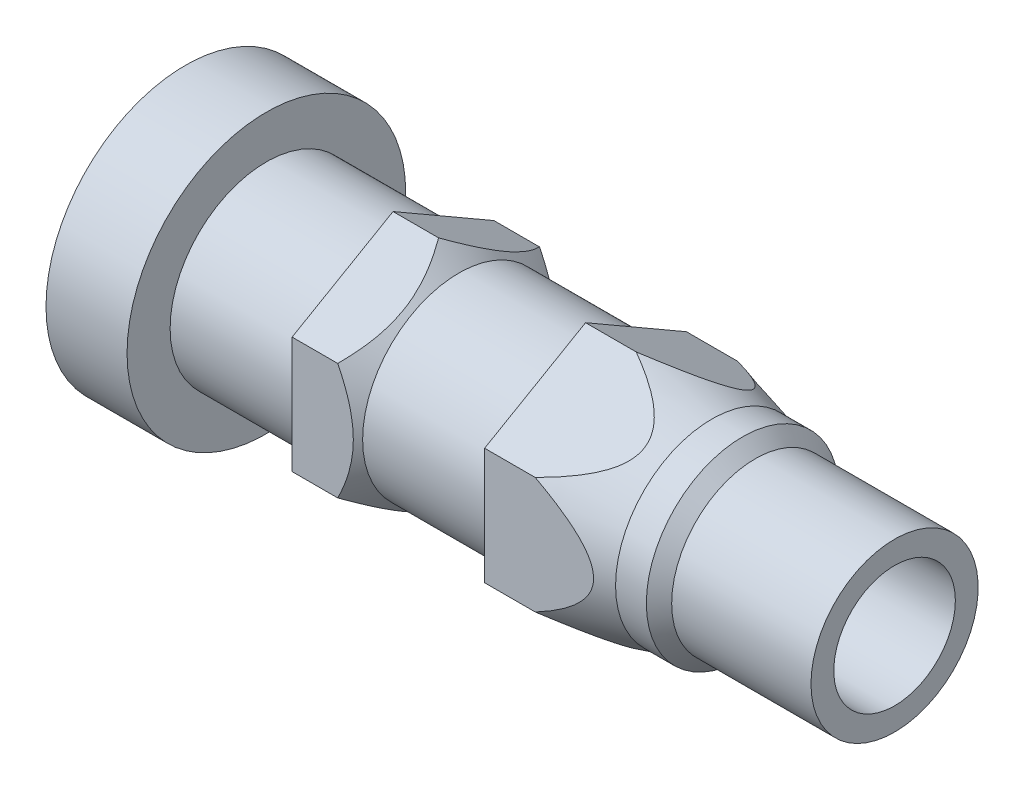
from build123d import *

# Parameters (mm, degrees)
HOLE1_D               = 0.7874
HOLE1_DEPTH           = 2.286
HOLE1_CSINK_D         = 1.016
HOLE1_CSINK_ANGLE     = 60
HOLE1_TIP             = 0.236558826
HOLE2_D               = 0.6096
SKETCH6_R             = 0.635
EXTRUSIONBLIND1_DEPTH = 1.6764


with BuildPart() as part:
    # Sketch1 → RevolutionAngle1 (revolve)
    with BuildSketch(Plane.XY):
        Polygon((0.4064, 0.4826), (1.0414, 0.4826), (1.0414, 0.5842), (1.27, 0.5842), (1.3716, 0.4826), (2.0066, 0.4826), (2.0066, 0.5842), (2.2606, 0.5842), (2.639776362, 0.4826), (2.794, 0.4826), (2.8575, 0.4191), (3.556, 0.4191), (3.556, 0), (0, 0), (0, 0.6985), (0.4064, 0.6985), align=None)
    revolve(axis=Axis((0, 0, 0), (1, 0, 0)))

    # Hole1
    with Locations(Plane.ZY):
        with Locations((0, 0)):
            CounterSinkHole(HOLE1_D / 2, HOLE1_CSINK_D / 2, depth=HOLE1_DEPTH, counter_sink_angle=HOLE1_CSINK_ANGLE)
            with Locations((0, 0, -(HOLE1_DEPTH + HOLE1_TIP / 2))):  # 118° drill point
                Cone(0, HOLE1_D / 2, HOLE1_TIP, mode=Mode.SUBTRACT)

    # Hole2 (through all)
    with Locations(Plane(origin=(3.556, 0, 0), x_dir=(0, 0, 1), z_dir=(1, 0, 0))):
        with Locations((0, 0)):
            Hole(HOLE2_D / 2)

    # Sketch6 → ExtrusionBlind1 (cut)
    with BuildSketch(Plane.ZY.offset(-1.0414)):
        Circle(SKETCH6_R)
        Polygon((0, 0.5842), (-0.505932041, 0.2921), (-0.505932041, -0.2921), (0, -0.5842), (0.505932041, -0.2921), (0.505932041, 0.2921), align=None, mode=Mode.SUBTRACT)
    extrude(amount=-EXTRUSIONBLIND1_DEPTH, mode=Mode.SUBTRACT)


solid = part.part
